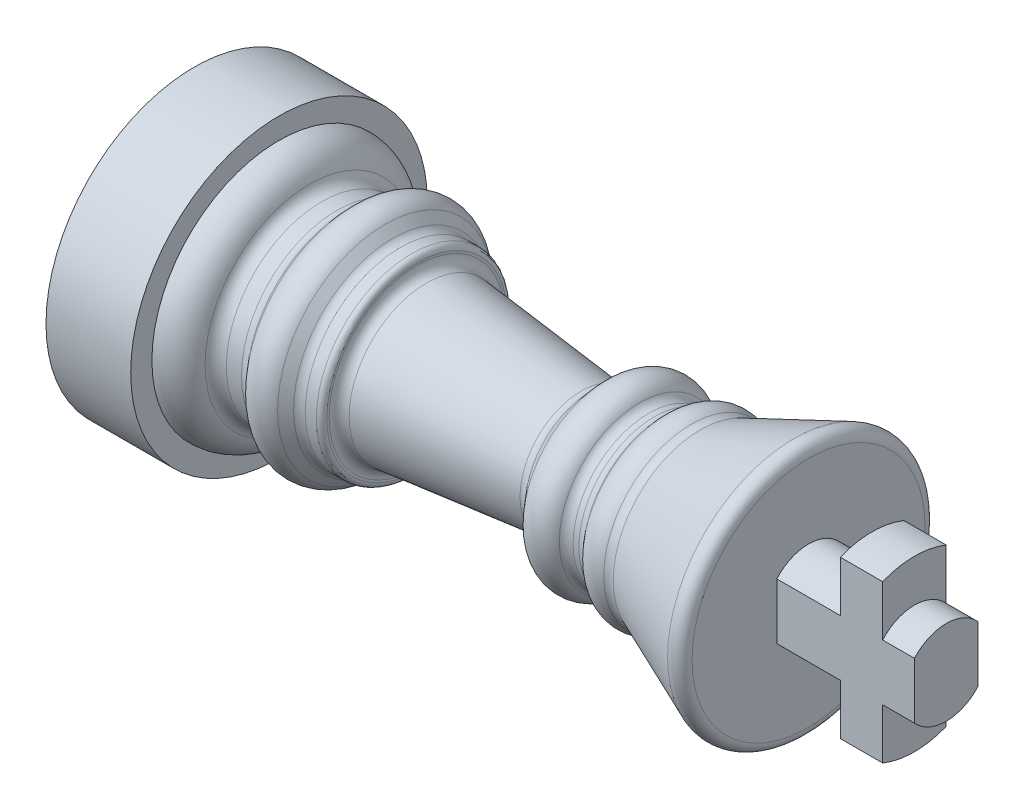
from build123d import *

# Parameters (mm, degrees)
FILETE8_R             = 0.25
ESBO_O2_OUTSIDE_W     = 21.78
ESBO_O2_OUTSIDE_H     = 21.78
ESBO_O2_OUTSIDE_W_2   = 3
ESBO_O2_OUTSIDE_H_2   = 9
CORTE_EXTRUS_O1_DEPTH = 6.5
CHANFRO1_SIZE         = 0.35
SKETCH1_R             = 7
BOSS_EXTRUDE1_DEPTH   = 3.5
SKETCH1_2_R           = 7
BOSS_EXTRUDE2_DEPTH   = 0.5
SKETCH2_R             = 6.05
CUT_EXTRUDE1_DEPTH    = 3.2


with BuildPart() as part:
    # Esboço1 → Revolução1 (revolve)
    with BuildSketch(Plane.XY):
        with BuildLine():
            Line((35, 0), (35, 2))
            Line((35, 2), (33.5, 2))
            Line((33.5, 2), (33.5, 4))
            Line((33.5, 4), (31.5, 4))
            Line((31.5, 4), (31.5, 2))
            Line((31.5, 2), (28.5, 2))
            Line((28.5, 2), (28.5, 5.5))
            ThreePointArc((28.5, 5.5), (28.277058526, 5.916219381), (27.807045707, 5.961268513))
            Line((27.807045707, 5.961268513), (23.39356896, 4.115056896))
            ThreePointArc((23.39356896, 4.115056896), (23.178174955, 4.076829203), (22.967076444, 4.134216939))
            ThreePointArc((22.967076444, 4.134216939), (22.316431993, 4.233007013), (21.74529042, 3.906059029))
            Line((21.74529042, 3.906059029), (21.597293402, 3.735807935))
            ThreePointArc((21.597293402, 3.735807935), (21.427285233, 3.608856815), (21.219938612, 3.56383745))
            Line((21.219938612, 3.56383745), (20.94780174, 3.56383745))
            ThreePointArc((20.94780174, 3.56383745), (20.708677896, 3.62472495), (20.527792665, 3.7925583))
            ThreePointArc((20.527792665, 3.7925583), (19.758767416, 4.247476821), (18.933064936, 3.906059029))
            Line((18.933064936, 3.906059029), (18.188720033, 3.049788169))
            ThreePointArc((18.188720033, 3.049788169), (17.994615856, 2.912608899), (17.759101011, 2.880556736))
            Line((17.759101011, 2.880556736), (10.458236719, 3.647908494))
            ThreePointArc((10.458236719, 3.647908494), (10.138928538, 3.810604138), (10.01050095, 4.145169441))
            Line((10.01050095, 4.145169441), (10.01050095, 4.5))
            Line((10.01050095, 4.5), (9.238364078, 4.5))
            ThreePointArc((9.238364078, 4.5), (9.031017457, 4.545019365), (8.861009288, 4.671970486))
            Line((8.861009288, 4.671970486), (8.51050095, 5.075184204))
            ThreePointArc((8.51050095, 5.075184204), (7.75579137, 5.419125175), (7.00108179, 5.075184204))
            Line((7.00108179, 5.075184204), (6.680471785, 4.706364583))
            ThreePointArc((6.680471785, 4.706364583), (6.476461982, 4.554023237), (6.227646037, 4.5))
            Line((6.227646037, 4.5), (5.51246118, 4.5))
            ThreePointArc((5.51246118, 4.5), (5.153892597, 4.618929765), (4.937472271, 4.928571429))
            ThreePointArc((4.937472271, 4.928571429), (4.396421457, 5.702675589), (3.5, 6))
            Line((3.5, 6), (0, 6))
            Line((0, 6), (0, 4.5))
            Line((0, 4.5), (0, 0))
            Line((0, 0), (35, 0))
        make_face()
    revolve(axis=Axis((0, 0, 0), (1, 0, 0)))

    # Filete8
    filete8_edges = [part.edges().sort_by_distance(p)[0] for p in [
        (10.01050095, -4.5, 0),
    ]]
    fillet(filete8_edges, radius=FILETE8_R)

    # Esboço2 outside → Corte-extrusão1 (cut)
    with BuildSketch(Plane(origin=(35, 0, 0), x_dir=(0, 0, -1), z_dir=(1, 0, 0))):
        Rectangle(ESBO_O2_OUTSIDE_W, ESBO_O2_OUTSIDE_H)
        Rectangle(ESBO_O2_OUTSIDE_W_2, ESBO_O2_OUTSIDE_H_2, mode=Mode.SUBTRACT)
    extrude(amount=-CORTE_EXTRUS_O1_DEPTH, mode=Mode.SUBTRACT)

    # Chanfro1
    chanfro1_edges = [part.edges().sort_by_distance(p)[0] for p in [
        (0, -6, 0),
    ]]
    chamfer(chanfro1_edges, length=CHANFRO1_SIZE)

    # Sketch1 → Boss-Extrude1 (add)
    with BuildSketch(Plane.ZY):
        Circle(SKETCH1_R)
    extrude(amount=-BOSS_EXTRUDE1_DEPTH)

    # Sketch1_2 → Boss-Extrude2 (add)
    with BuildSketch(Plane.ZY):
        Circle(SKETCH1_2_R)
    extrude(amount=BOSS_EXTRUDE2_DEPTH)

    # Sketch2 → Cut-Extrude1 (cut)
    with BuildSketch(Plane.ZY.offset(0.5)):
        Circle(SKETCH2_R)
    extrude(amount=-CUT_EXTRUDE1_DEPTH, mode=Mode.SUBTRACT)


solid = part.part
